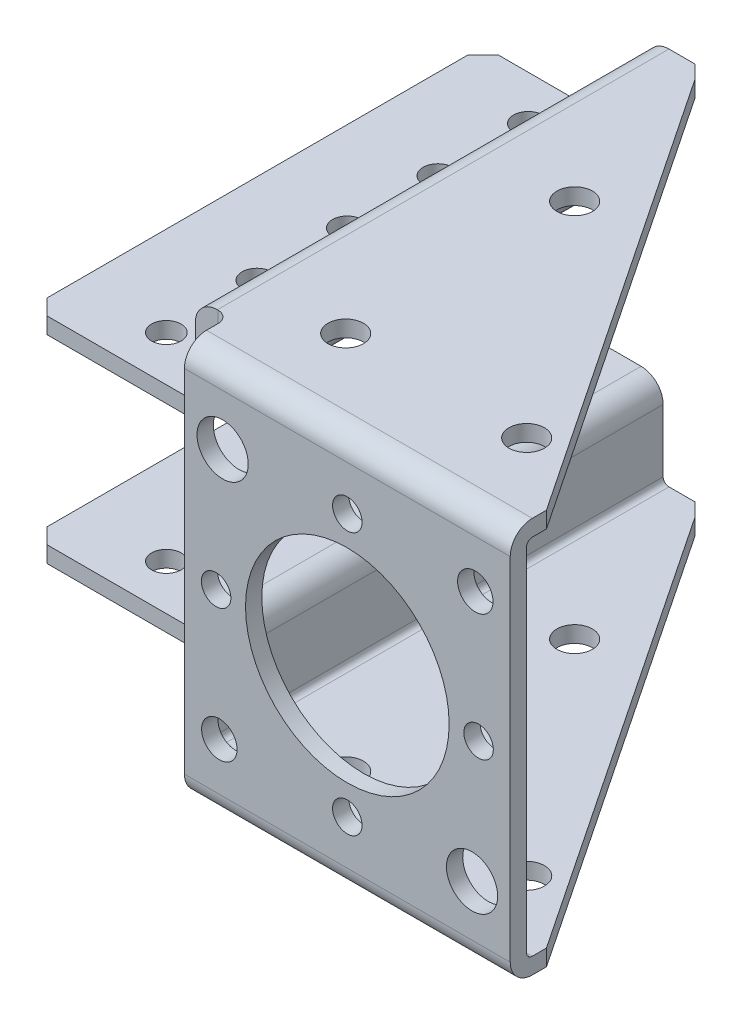
from build123d import *

# Parameters (mm, degrees)
SKETCH1_W                  = 43.18
SKETCH1_H                  = 50.927
BOSS_EXTRUDE1_DEPTH        = 5.08
BOSS_EXTRUDE2_DEPTH        = 2.286
BOSS_EXTRUDE3_DEPTH        = 2.286
SKETCH4_W                  = 43.18
SKETCH4_H                  = 50.927
CUT_EXTRUDE1_DEPTH         = 2.794
BOSS_EXTRUDE4_DEPTH        = 2.54
SKETCH6_W                  = 63.373
SKETCH6_H                  = 2.286
BOSS_EXTRUDE5_DEPTH        = 27.813
SKETCH7_W                  = 25.273
SKETCH7_H                  = 63.373
BOSS_EXTRUDE6_DEPTH        = 12.7
SKETCH8_W                  = 63.373
SKETCH8_H                  = 2.286
BOSS_EXTRUDE7_DEPTH        = 27.813
SKETCH9_W                  = 25.273
SKETCH9_H                  = 63.373
BOSS_EXTRUDE8_DEPTH        = 12.7
SKETCH10_W                 = 22.987
SKETCH10_H                 = 12.7
CUT_EXTRUDE2_DEPTH         = 70.723
SKETCH11_W                 = 22.987
SKETCH11_H                 = 12.7
CUT_EXTRUDE3_DEPTH         = 70.723
HOLE1_D                    = 4.9784
HOLE1_DEPTH                = 2.286
M3_5_CLEARANCE_HOLE1_D     = 4.1402
M3_5_CLEARANCE_HOLE1_DEPTH = 69.723
M3_5_CLEARANCE_HOLE2_D     = 4.1402
M3_5_CLEARANCE_HOLE2_DEPTH = 2.286025
M25_CLEARANCE_HOLE1_D      = 28.575
M25_CLEARANCE_HOLE1_DEPTH  = 2.286025
M6_5_CLEARANCE_HOLE1_D     = 7.1882
M6_5_CLEARANCE_HOLE1_DEPTH = 2.286025
HOLE2_D                    = 4.9784
HOLE2_DEPTH                = 2.286025
M3_5_CLEARANCE_HOLE3_D     = 4.1402
M3_5_CLEARANCE_HOLE3_DEPTH = 2.286
HOLE3_D                    = 4.9784
HOLE3_DEPTH                = 2.28605
M3_5_CLEARANCE_HOLE4_D     = 4.1402
M3_5_CLEARANCE_HOLE4_DEPTH = 14.98605
CHAMFER1_SIZE2             = 0.596085437
CHAMFER1_SIZE              = 2.159
CHAMFER2_SIZE              = 2.159
CHAMFER3_SIZE              = 2.159
CHAMFER3_SIZE2             = 0.596085437
FILLET1_R                  = 0.8128
FILLET2_R                  = 1.6256
FILLET3_R                  = 3.0988


with BuildPart() as part:
    # Sketch1 → Boss-Extrude1 (new body)
    with BuildSketch(Plane.XY.offset(2.286)):
        with Locations((1.27, 0)):
            Rectangle(SKETCH1_W, SKETCH1_H)
    extrude(amount=-BOSS_EXTRUDE1_DEPTH)

    # Sketch2 → Boss-Extrude2 (add)
    with BuildSketch(Plane(origin=(0, 25.4635, 0), x_dir=(-1, 0, 0), z_dir=(0, 1, 0))):
        Polygon((20.32, 2.286), (20.32, -67.437), (-22.86, -2.794), (-22.86, 2.286), align=None)
    extrude(amount=BOSS_EXTRUDE2_DEPTH)

    # Sketch3 → Boss-Extrude3 (add)
    with BuildSketch(Plane.XZ.offset(25.4635)):
        Polygon((-20.32, -67.437), (-20.32, 2.286), (22.86, 2.286), (22.86, -2.794), align=None)
    extrude(amount=BOSS_EXTRUDE3_DEPTH)

    # Sketch4 → Cut-Extrude1 (cut)
    with BuildSketch(Plane(origin=(0, 0, -2.794), x_dir=(-1, 0, 0), z_dir=(0, 0, -1))):
        with Locations((-1.27, 0)):
            Rectangle(SKETCH4_W, SKETCH4_H)
    extrude(amount=-CUT_EXTRUDE1_DEPTH, mode=Mode.SUBTRACT)

    # Sketch5 → Boss-Extrude4 (add)
    with BuildSketch(Plane.ZY.offset(20.32)):
        Polygon((-67.437, -25.4635), (0, -25.4635), (0, 25.4635), (-67.437, 25.4635), (-67.437, 27.7495), (2.286, 27.7495), (2.286, -27.7495), (-67.437, -27.7495), align=None)
    extrude(amount=BOSS_EXTRUDE4_DEPTH)

    # Sketch6 → Boss-Extrude5 (add)
    with BuildSketch(Plane.ZY.offset(22.86)):
        with Locations((-35.7505, 26.6065)):
            Rectangle(SKETCH6_W, SKETCH6_H)
    extrude(amount=BOSS_EXTRUDE5_DEPTH)

    # Sketch7 → Boss-Extrude6 (add)
    with BuildSketch(Plane.XZ.offset(-25.4635)):
        with Locations((-38.0365, -35.7505)):
            Rectangle(SKETCH7_W, SKETCH7_H)
    extrude(amount=BOSS_EXTRUDE6_DEPTH)

    # Sketch8 → Boss-Extrude7 (add)
    with BuildSketch(Plane.ZY.offset(22.86)):
        with Locations((-35.7505, -26.6065)):
            Rectangle(SKETCH8_W, SKETCH8_H)
    extrude(amount=BOSS_EXTRUDE7_DEPTH)

    # Sketch9 → Boss-Extrude8 (add)
    with BuildSketch(Plane(origin=(0, -25.4635, 0), x_dir=(-1, 0, 0), z_dir=(0, 1, 0))):
        with Locations((38.0365, -35.7505)):
            Rectangle(SKETCH9_W, SKETCH9_H)
    extrude(amount=BOSS_EXTRUDE8_DEPTH)

    # Sketch10 → Cut-Extrude2 (cut, through all)
    with BuildSketch(Plane(origin=(0, 0, -67.437), x_dir=(-1, 0, 0), z_dir=(0, 0, -1))):
        with Locations((39.1795, 21.3995)):
            Rectangle(SKETCH10_W, SKETCH10_H)
    extrude(amount=-CUT_EXTRUDE2_DEPTH, mode=Mode.SUBTRACT)

    # Sketch11 → Cut-Extrude3 (cut, through all)
    with BuildSketch(Plane(origin=(0, 0, -67.437), x_dir=(-1, 0, 0), z_dir=(0, 0, -1))):
        with Locations((39.1795, -21.3995)):
            Rectangle(SKETCH11_W, SKETCH11_H)
    extrude(amount=-CUT_EXTRUDE3_DEPTH, mode=Mode.SUBTRACT)

    # Hole1
    with Locations(Plane(origin=(0, -27.7495, 0), x_dir=(-1, 0, 0), z_dir=(0, -1, 0))):
        with Locations((12.7, 10.1854), (-12.7, 10.1854), (12.7, 42.3164)):
            Hole(HOLE1_D / 2, depth=HOLE1_DEPTH)

    # M3.5 Clearance Hole1
    with Locations(Plane.XY.offset(2.286)):
        with Locations((0, -18.415)):
            Hole(M3_5_CLEARANCE_HOLE1_D / 2, depth=M3_5_CLEARANCE_HOLE1_DEPTH)

    # M3.5 Clearance Hole2
    with Locations(Plane(origin=(0, 0, 0), x_dir=(-1, 0, 0), z_dir=(0, 0, -1))):
        with Locations((-18.415, 0), (18.415, 0), (0, 18.415)):
            Hole(M3_5_CLEARANCE_HOLE2_D / 2, depth=M3_5_CLEARANCE_HOLE2_DEPTH)

    # M25 Clearance Hole1
    with Locations(Plane(origin=(0, 0, 0), x_dir=(-1, 0, 0), z_dir=(0, 0, -1))):
        with Locations((0, 0)):
            Hole(M25_CLEARANCE_HOLE1_D / 2, depth=M25_CLEARANCE_HOLE1_DEPTH)

    # M6.5 Clearance Hole1
    with Locations(Plane(origin=(0, 0, 0), x_dir=(-1, 0, 0), z_dir=(0, 0, -1))):
        with Locations((17.5, 17.5), (-17.5, -17.5)):
            Hole(M6_5_CLEARANCE_HOLE1_D / 2, depth=M6_5_CLEARANCE_HOLE1_DEPTH)

    # Hole2
    with Locations(Plane(origin=(0, 0, 0), x_dir=(-1, 0, 0), z_dir=(0, 0, -1))):
        with Locations((17.960512242, -17.960512242), (-17.960512242, 17.960512242)):
            Hole(HOLE2_D / 2, depth=HOLE2_DEPTH)

    # M3.5 Clearance Hole3
    with Locations(Plane(origin=(0, -15.0495, 0), x_dir=(-1, 0, 0), z_dir=(0, -1, 0))):
        with Locations((38.1, 61.214), (38.1, 48.514), (38.1, 35.814), (38.1, 23.114), (38.1, 10.414)):
            Hole(M3_5_CLEARANCE_HOLE3_D / 2, depth=M3_5_CLEARANCE_HOLE3_DEPTH)

    # Hole3
    with Locations(Plane(origin=(0, 25.4635, 0), x_dir=(-1, 0, 0), z_dir=(0, -1, 0))):
        with Locations((12.7, 10.1854), (-12.7, 10.1854), (12.7, 42.3164)):
            Hole(HOLE3_D / 2, depth=HOLE3_DEPTH)

    # M3.5 Clearance Hole4
    with Locations(Plane(origin=(0, 12.7635, 0), x_dir=(-1, 0, 0), z_dir=(0, -1, 0))):
        with Locations((38.1, 61.214), (38.1, 48.514), (38.1, 35.814), (38.1, 23.114), (38.1, 10.414)):
            Hole(M3_5_CLEARANCE_HOLE4_D / 2, depth=M3_5_CLEARANCE_HOLE4_DEPTH)

    # Chamfer1
    chamfer1_edges = [part.edges().sort_by_distance(p)[0] for p in [
        (-20.32, 26.6065, -67.437),
    ]]
    chamfer(chamfer1_edges, length=CHAMFER1_SIZE, length2=CHAMFER1_SIZE2)

    # Chamfer2
    chamfer2_edges = [part.edges().sort_by_distance(p)[0] for p in [
        (-50.673, -13.9065, -67.437),
        (-50.673, 13.9065, -67.437),
        (-50.673, -13.9065, -4.064),
        (-50.673, 13.9065, -4.064),
    ]]
    chamfer(chamfer2_edges, length=CHAMFER2_SIZE)

    # Chamfer3
    chamfer3_edges = [part.edges().sort_by_distance(p)[0] for p in [
        (-20.32, -26.6065, -67.437),
    ]]
    chamfer3_side = [part.faces().sort_by_distance(p)[0] for p in [
        (1.27, -26.6065, -35.1155),
    ]]
    chamfer(chamfer3_edges, length=CHAMFER3_SIZE, length2=CHAMFER3_SIZE2, reference=chamfer3_side[0])

    # Fillet1
    fillet1_edges = [part.edges().sort_by_distance(p)[0] for p in [
        (0, -25.4635, 0),
        (-25.4, 25.4635, -35.7505),
        (-25.4, -25.4635, -35.7505),
        (-27.686, -15.0495, -35.7505),
        (-27.686, 15.0495, -35.7505),
        (0, 25.4635, 0),
    ]]
    fillet(fillet1_edges, radius=FILLET1_R)

    # Fillet2
    fillet2_edges = [part.edges().sort_by_distance(p)[0] for p in [
        (-22.86, -26.6065, -4.064),
        (-22.86, 26.6065, -4.064),
    ]]
    fillet(fillet2_edges, radius=FILLET2_R)

    # Fillet3
    fillet3_edges = [part.edges().sort_by_distance(p)[0] for p in [
        (0, 27.7495, 2.286),
        (-27.686, -27.7495, -35.7505),
        (0, -27.7495, 2.286),
        (-25.4, 12.7635, -35.7505),
        (-25.4, -12.7635, -35.7505),
        (-27.686, 27.7495, -35.7505),
    ]]
    fillet(fillet3_edges, radius=FILLET3_R)


solid = part.part
